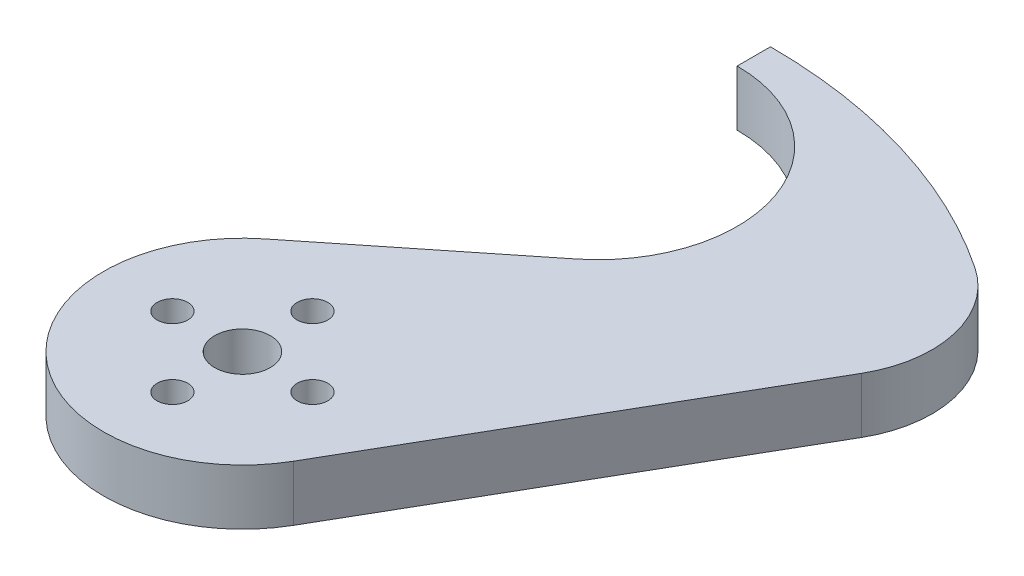
from build123d import *

# Parameters (mm, degrees)
SKETCH1_R           = 3.175
BOSS_EXTRUDE1_DEPTH = 6.35
SKETCH2_R           = 1.75
CUT_EXTRUDE1_DEPTH  = 7.35
CIRPATTERN1_COUNT   = 4
FILLET1_R           = 12.7


with BuildPart() as part:
    # Sketch1 → Boss-Extrude1 (new body)
    with BuildSketch(Plane(origin=(0, 0, 0), x_dir=(1, 0, 0), z_dir=(0, 1, 0))):
        with BuildLine():
            Line((13.748153285, -7.9375), (42.847508948, 42.464062476))
            ThreePointArc((42.847508948, 42.464062476), (23.210569318, 55.681011996), (0, 60.325))
            Line((0, 60.325), (0, 56.515))
            ThreePointArc((0, 56.515), (14.981702707, 45.890162758), (9.909464895, 28.23765625))
            Line((9.909464895, 28.23765625), (-9.909464895, 12.40234375))
            ThreePointArc((-9.909464895, 12.40234375), (-10.349453758, -12.037625676), (13.748153285, -7.9375))
        make_face()
        Circle(SKETCH1_R, mode=Mode.SUBTRACT)
    extrude(amount=BOSS_EXTRUDE1_DEPTH)

    # Sketch2 → Cut-Extrude1 (cut, through all)
    with BuildSketch(Plane(origin=(0, 6.35, 0), x_dir=(1, 0, 0), z_dir=(0, 1, 0))):
        with Locations((8, 0)):
            Circle(SKETCH2_R)
    cut_extrude1 = extrude(amount=-CUT_EXTRUDE1_DEPTH, mode=Mode.SUBTRACT)

    # CirPattern1: Cut-Extrude1 ×4 about axis
    cirpattern1_axis = Axis((0, 0, 0), (0, 1, 0))
    for i in range(1, CIRPATTERN1_COUNT):
        add(cut_extrude1.rotate(cirpattern1_axis, i * 360 / CIRPATTERN1_COUNT), mode=Mode.SUBTRACT)

    # Fillet1
    fillet1_edges = [part.edges().sort_by_distance(p)[0] for p in [
        (42.847508948, 3.175, -42.464062476),
    ]]
    fillet(fillet1_edges, radius=FILLET1_R)


solid = part.part
